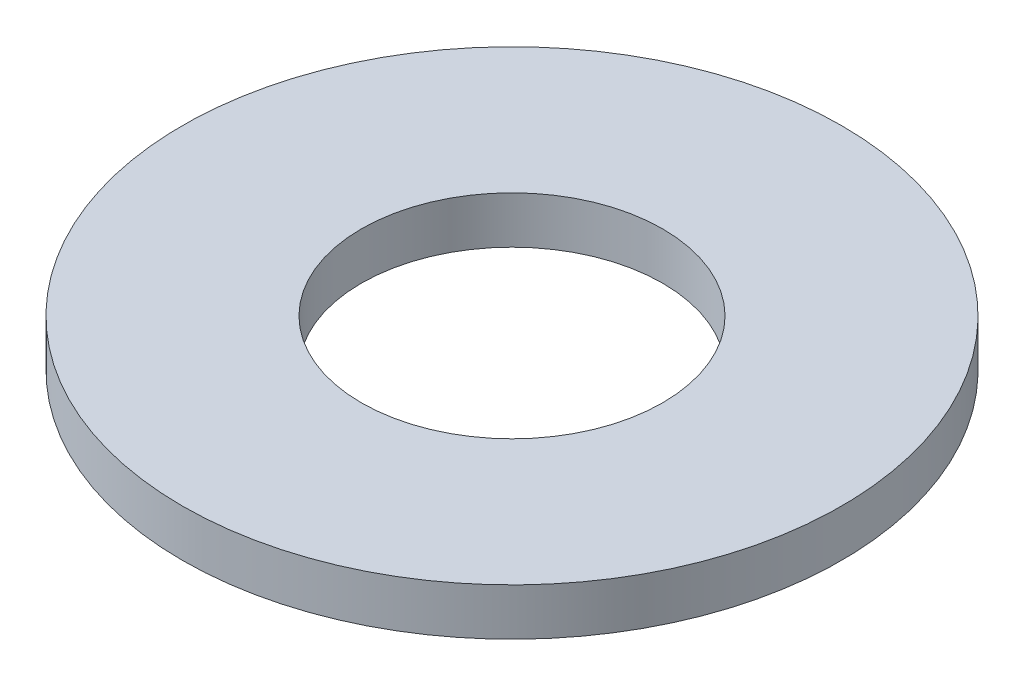
from build123d import *

# Parameters (mm, degrees)
ESBO_O1_R                = 3.5
ESBO_O1_R_2              = 1.6
RESSALTO_EXTRUS_O1_DEPTH = 0.5


with BuildPart() as part:
    # Esboço1 → Ressalto-extrusão1 (new body)
    with BuildSketch(Plane(origin=(0, 0, 0), x_dir=(1, 0, 0), z_dir=(0, 1, 0))):
        Circle(ESBO_O1_R)
        Circle(ESBO_O1_R_2, mode=Mode.SUBTRACT)
    extrude(amount=RESSALTO_EXTRUS_O1_DEPTH)


solid = part.part
